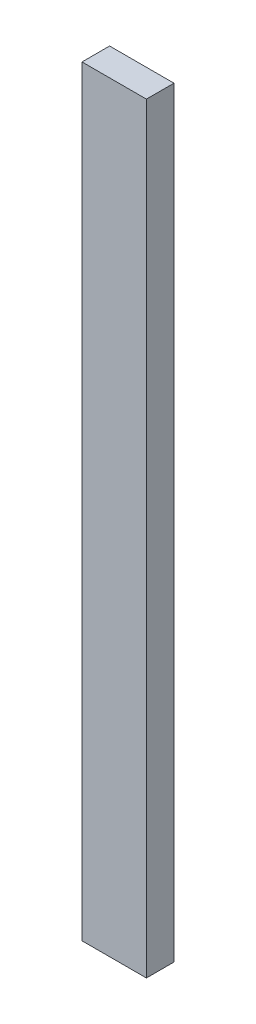
from build123d import *

# Parameters (mm, degrees)
SKETCH1_W           = 88.9
SKETCH1_H           = 38.1
BOSS_EXTRUDE1_DEPTH = 1050.925


with BuildPart() as part:
    # Sketch1 → Boss-Extrude1 (new body)
    with BuildSketch(Plane(origin=(0, 0, 0), x_dir=(1, 0, 0), z_dir=(0, 1, 0))):
        Rectangle(SKETCH1_W, SKETCH1_H)
    extrude(amount=BOSS_EXTRUDE1_DEPTH)


solid = part.part
